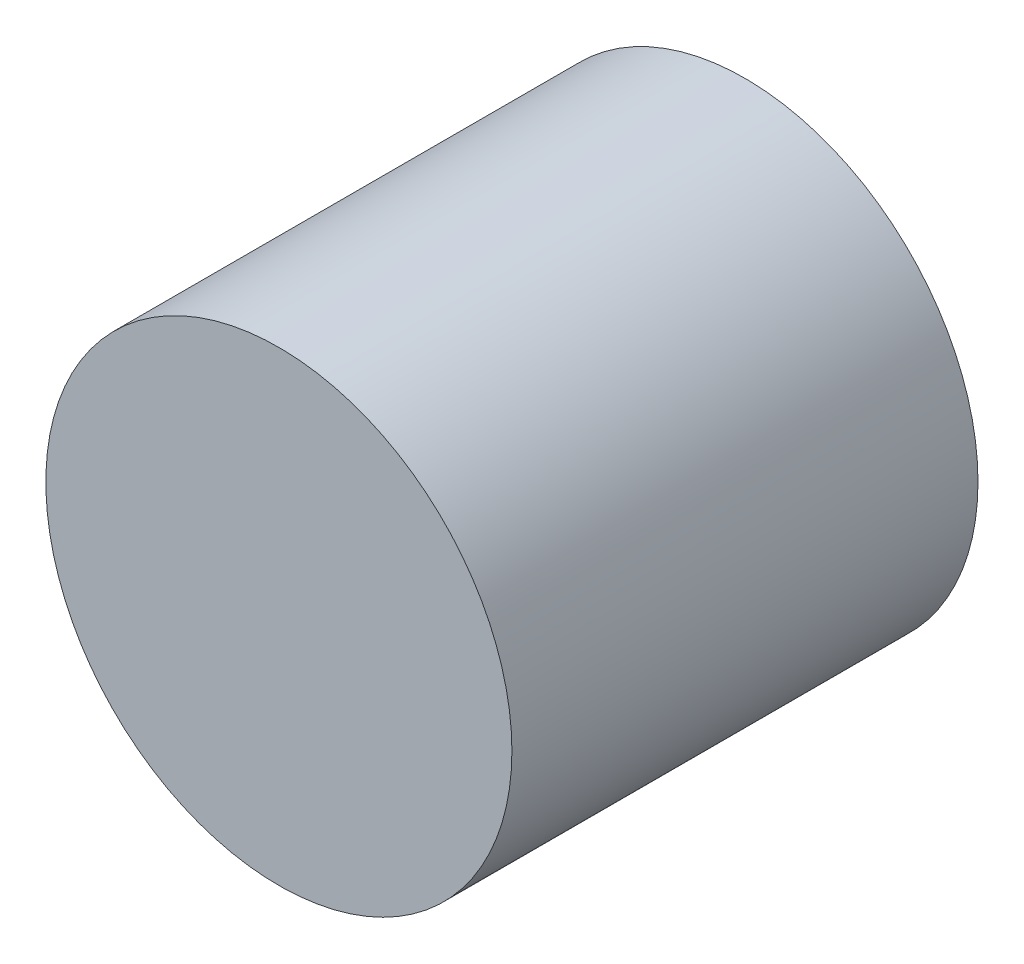
from build123d import *

# Parameters (mm, degrees)
SKETCH1_R           = 25.4
BOSS_EXTRUDE1_DEPTH = 50.8


with BuildPart() as part:
    # Sketch1 → Boss-Extrude1 (new body)
    with BuildSketch(Plane.XY):
        Circle(SKETCH1_R)
    extrude(amount=BOSS_EXTRUDE1_DEPTH)


solid = part.part
